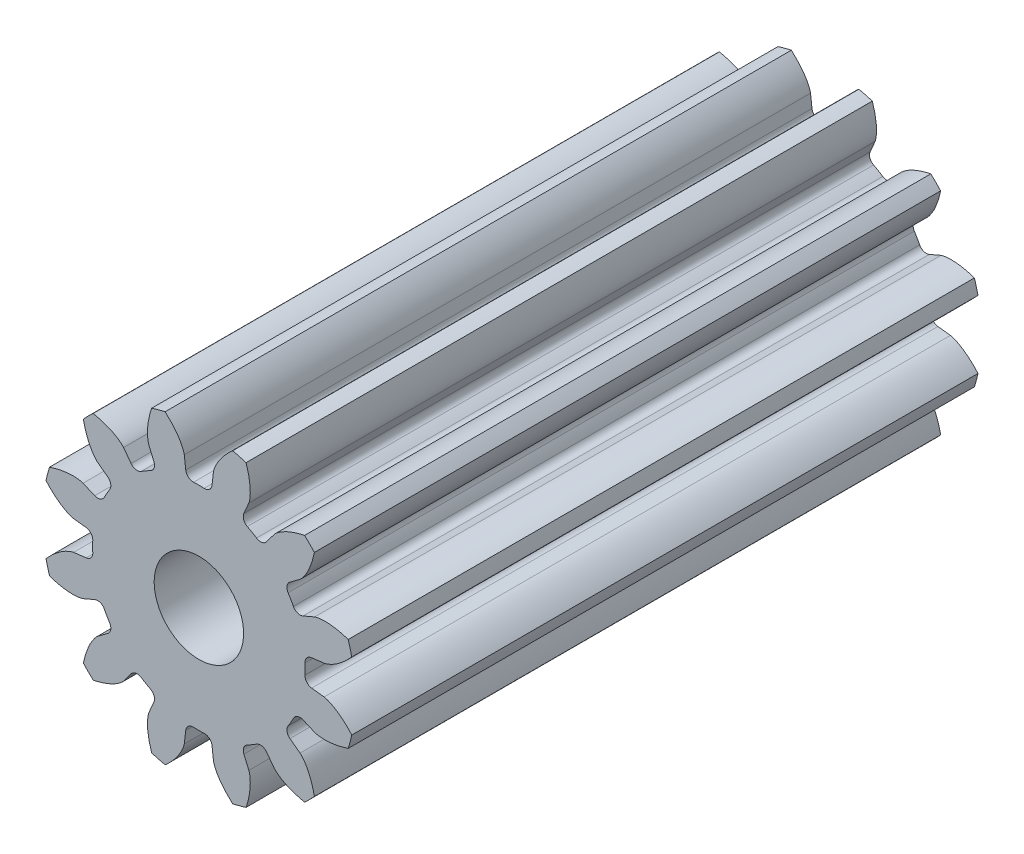
from build123d import *

# Parameters (mm, degrees)
SKETCH3_R                    = 5.55625
BOSS_EXTRUDE1_DEPTH          = 152.4
BOSS_EXTRUDE1_DEPTH_BACK     = 152.4
CUT_EXTRUDE1_DEPTH           = 153.4
FILLET1_R                    = 0.266307122
CIRPATTERN1_COUNT            = 12
FILLET1_OF_CIRPATTERN1_R     = 0.266307122
SKETCH6_R                    = 6.35
CUT_EXTRUDE2_DEPTH           = 282.575
F_1_8_0_125_DIAMETER_HOLE1_D = 3.175


with BuildPart() as part:
    # Sketch3 → Boss-Extrude1 (new body, two sides)
    with BuildSketch(Plane.XY) as boss_extrude1_sk:
        Circle(SKETCH3_R)
    extrude(amount=BOSS_EXTRUDE1_DEPTH)
    extrude(boss_extrude1_sk.sketch, amount=-BOSS_EXTRUDE1_DEPTH_BACK)

    # Sketch4 → Cut-Extrude1 (cut, symmetric)
    with BuildSketch(Plane.XY):
        with BuildLine():
            Line((3.744976316, 0.436358502), (4.445212559, 0.517948881))
            add(Edge.make_bspline(
                [(4.445212559, 0.517948881), (4.446988643, 0.518183904), (4.451958486, 0.518928669), (4.461305965, 0.520674333), (4.476476085, 0.52400013), (4.495673135, 0.528937043), (4.520313723, 0.536116762), (4.54910084, 0.54559681), (4.580461748, 0.557079488), (4.61425939, 0.570712843), (4.647674072, 0.585316581), (4.680706871, 0.600810831), (4.713330756, 0.617076935), (4.752496873, 0.637754625), (4.798959577, 0.663898969), (4.852488387, 0.696400297), (4.912241535, 0.735537021), (4.972050732, 0.777818405), (5.029985943, 0.821379591), (5.087404852, 0.86760016), (5.142164542, 0.913883496), (5.197824541, 0.964166137), (5.248586848, 1.011708006), (5.304042495, 1.067362637), (5.348387699, 1.112979688), (5.39297093, 1.162057664), (5.414486972, 1.186230835), (5.425405133, 1.198704801)],
                knots=[0, 0, 0, 0, 0, 0.005376749, 0.015083688, 0.02853182, 0.046610139, 0.064854849, 0.092110525, 0.119476176, 0.146842496, 0.174208854, 0.201574956, 0.228941013, 0.256307345, 0.307035032, 0.361767352, 0.416499661, 0.471231937, 0.525964282, 0.580696615, 0.635428982, 0.690161387, 0.744893688, 0.799626082, 0.854358408, 0.909090915, 0.909090915, 0.909090915, 0.909090915, 0.909090915], degree=4))
            ThreePointArc((5.425405133, 1.198704801), (5.55625, 0), (5.425405133, -1.198704801))
            add(Edge.make_bspline(
                [(4.445212559, -0.517948881), (4.446988643, -0.518183904), (4.451958486, -0.518928669), (4.461305965, -0.520674333), (4.476476085, -0.52400013), (4.495673135, -0.528937043), (4.520313723, -0.536116762), (4.54910084, -0.54559681), (4.580461748, -0.557079488), (4.61425939, -0.570712843), (4.647674072, -0.585316581), (4.680706871, -0.600810831), (4.713330756, -0.617076935), (4.752496873, -0.637754625), (4.798959577, -0.663898969), (4.852488387, -0.696400297), (4.912241535, -0.735537021), (4.972050732, -0.777818405), (5.029985943, -0.821379591), (5.087404852, -0.86760016), (5.142164542, -0.913883496), (5.197824541, -0.964166137), (5.248586848, -1.011708006), (5.304042495, -1.067362637), (5.348387699, -1.112979688), (5.39297093, -1.162057664), (5.414486972, -1.186230835), (5.425405133, -1.198704801)],
                knots=[0, 0, 0, 0, 0, 0.005376749, 0.015083688, 0.02853182, 0.046610139, 0.064854849, 0.092110525, 0.119476176, 0.146842496, 0.174208854, 0.201574956, 0.228941013, 0.256307345, 0.307035032, 0.361767352, 0.416499661, 0.471231937, 0.525964282, 0.580696615, 0.635428982, 0.690161387, 0.744893688, 0.799626082, 0.854358408, 0.909090915, 0.909090915, 0.909090915, 0.909090915, 0.909090915], degree=4))
            Line((4.445212559, -0.517948881), (3.744976316, -0.436358502))
            ThreePointArc((3.744976316, -0.436358502), (3.7703125, 0), (3.744976316, 0.436358502))
        make_face()
    cut_extrude1 = extrude(amount=CUT_EXTRUDE1_DEPTH, both=True, mode=Mode.SUBTRACT)

    # Fillet1
    fillet1_edges = [part.edges().sort_by_distance(p)[0] for p in [
        (3.744976316, -0.436358502, 0),
        (3.744976316, 0.436358502, 0),
    ]]
    fillet(fillet1_edges, radius=FILLET1_R)

    # CirPattern1: Cut-Extrude1 ×12 about axis
    cirpattern1_axis = Axis((0, 0, 152.4), (0, 0, -1))
    for i in range(1, CIRPATTERN1_COUNT):
        add(cut_extrude1.rotate(cirpattern1_axis, i * 360 / CIRPATTERN1_COUNT), mode=Mode.SUBTRACT)

    # Fillet1 of CirPattern1
    fillet1_of_cirpattern1_edges = [part.edges().sort_by_distance(p)[0] for p in [
        (3.025065375, -2.250385705, 0),
        (3.461423877, -1.49459061, 0),
        (1.49459061, -3.461423877, 0),
        (2.250385705, -3.025065375, 0),
        (-0.436358502, -3.744976316, 0),
        (0.436358502, -3.744976316, 0),
        (-2.250385705, -3.025065375, 0),
        (-1.49459061, -3.461423877, 0),
        (-3.461423877, -1.49459061, 0),
        (-3.025065375, -2.250385705, 0),
        (-3.744976316, 0.436358502, 0),
        (-3.744976316, -0.436358502, 0),
        (-3.025065375, 2.250385705, 0),
        (-3.461423877, 1.49459061, 0),
        (-1.49459061, 3.461423877, 0),
        (-2.250385705, 3.025065375, 0),
        (0.436358502, 3.744976316, 0),
        (-0.436358502, 3.744976316, 0),
        (2.250385705, 3.025065375, 0),
        (1.49459061, 3.461423877, 0),
        (3.461423877, 1.49459061, 0),
        (3.025065375, 2.250385705, 0),
    ]]
    fillet(fillet1_of_cirpattern1_edges, radius=FILLET1_OF_CIRPATTERN1_R)

    # Sketch6 → Cut-Extrude2 (cut)
    with BuildSketch(Plane.XY.offset(152.4)):
        Circle(SKETCH6_R)
    extrude(amount=-CUT_EXTRUDE2_DEPTH, mode=Mode.SUBTRACT)

    # 1/8 (0.125) Diameter Hole1 (through all)
    with Locations(Plane(origin=(0, 0, -152.4), x_dir=(-1, 0, 0), z_dir=(0, 0, -1))):
        with Locations((0, 0)):
            Hole(F_1_8_0_125_DIAMETER_HOLE1_D / 2)


solid = part.part
